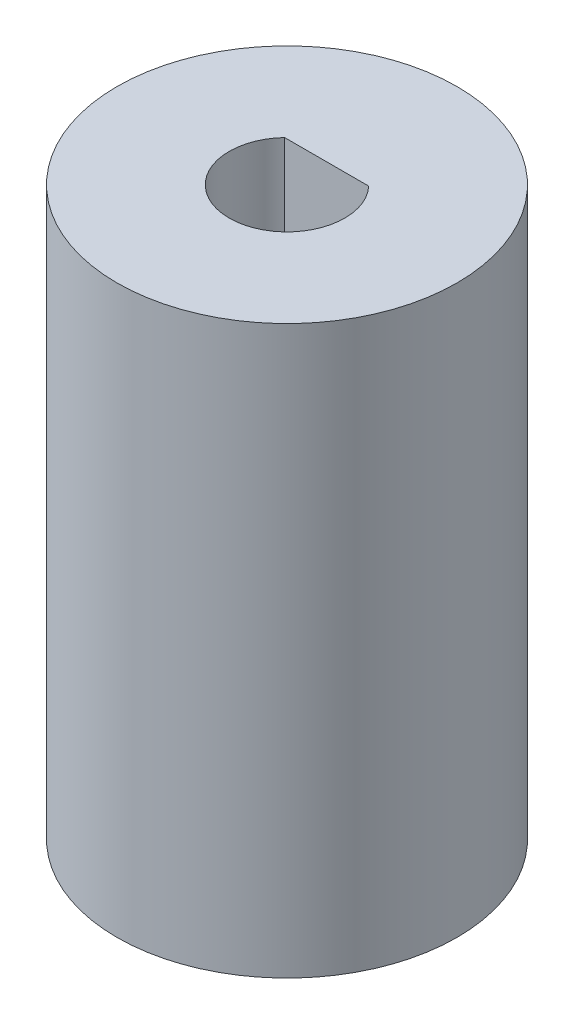
from build123d import *

# Parameters (mm, degrees)
SKETCH1_R           = 15
BOSS_EXTRUDE1_DEPTH = 50
CUT_EXTRUDE1_DEPTH  = 20
CUT_EXTRUDE2_DEPTH  = 30


with BuildPart() as part:
    # Sketch1 → Boss-Extrude1 (new body)
    with BuildSketch(Plane(origin=(0, 0, 0), x_dir=(1, 0, 0), z_dir=(0, 1, 0))):
        Circle(SKETCH1_R)
    extrude(amount=BOSS_EXTRUDE1_DEPTH)

    # Sketch2 → Cut-Extrude1 (cut)
    with BuildSketch(Plane(origin=(0, 50, 0), x_dir=(1, 0, 0), z_dir=(0, 1, 0))):
        with BuildLine():
            Line((-3.709447398, 3.5), (3.709447398, 3.5))
            ThreePointArc((3.709447398, 3.5), (0, -5.1), (-3.709447398, 3.5))
        make_face()
    extrude(amount=-CUT_EXTRUDE1_DEPTH, mode=Mode.SUBTRACT)

    # Sketch3 → Cut-Extrude2 (cut)
    with BuildSketch(Plane.XZ):
        Polygon((-6.5, 0), (-3.25, 5.629165125), (3.25, 5.629165125), (6.5, 0), (3.25, -5.629165125), (-3.25, -5.629165125), align=None)
    extrude(amount=-CUT_EXTRUDE2_DEPTH, mode=Mode.SUBTRACT)


solid = part.part
